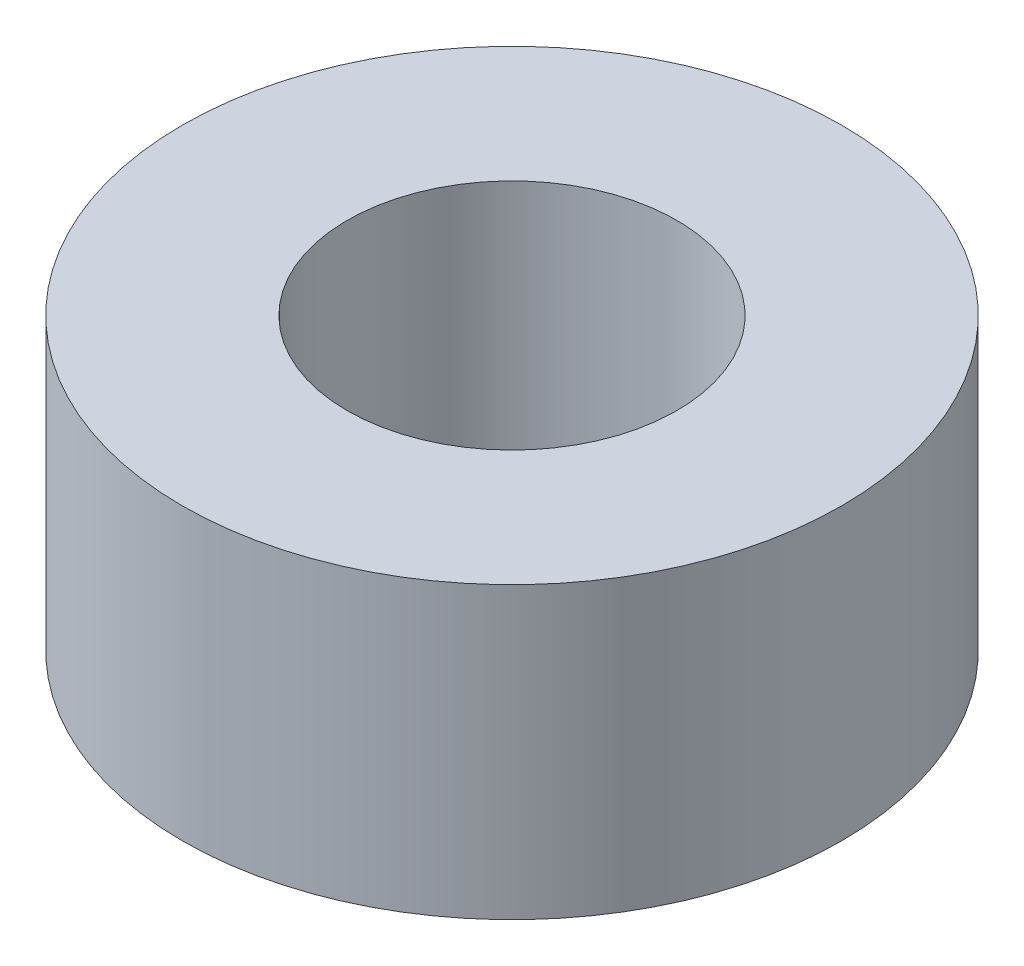
from build123d import *

# Parameters (mm, degrees)
SKETCH1_R           = 6.35
SKETCH1_R_2         = 3.175
BOSS_EXTRUDE1_DEPTH = 5.588


with BuildPart() as part:
    # Sketch1 → Boss-Extrude1 (new body)
    with BuildSketch(Plane(origin=(0, 0, 0), x_dir=(1, 0, 0), z_dir=(0, 1, 0))):
        Circle(SKETCH1_R)
        Circle(SKETCH1_R_2, mode=Mode.SUBTRACT)
    extrude(amount=BOSS_EXTRUDE1_DEPTH)


solid = part.part
